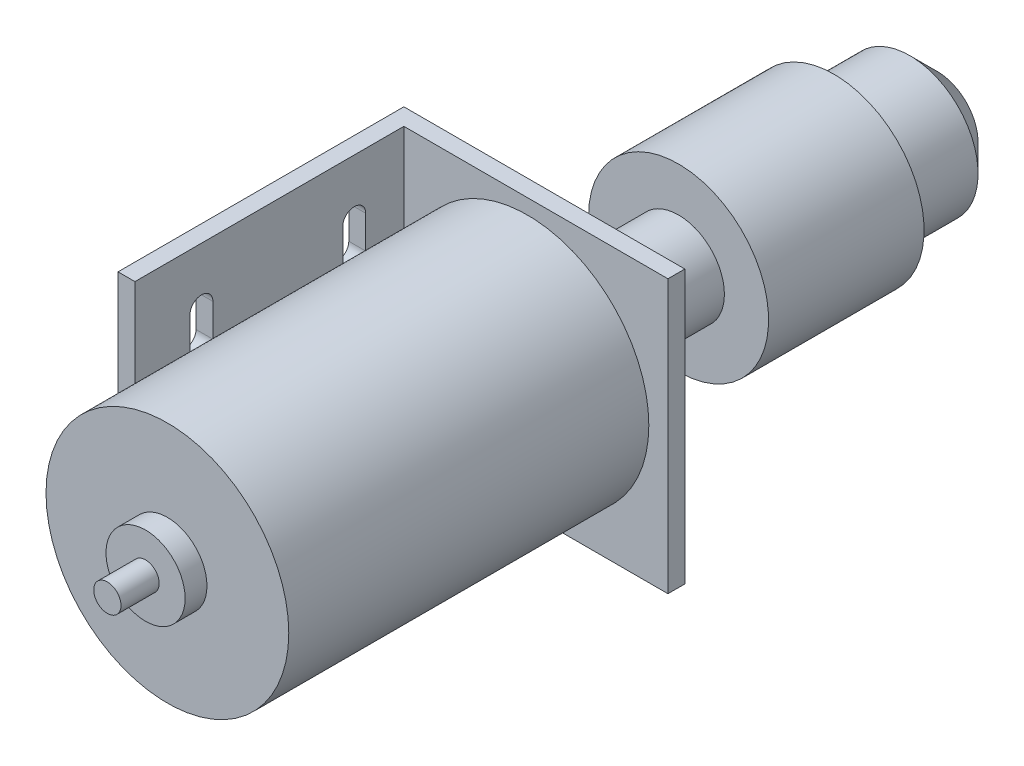
from build123d import *

# Parameters (mm, degrees)
SKETCH1_R           = 22.25
BOSS_EXTRUDE1_DEPTH = 66
SKETCH2_R           = 7.25
BOSS_EXTRUDE2_DEPTH = 4
SKETCH3_R           = 2.5
BOSS_EXTRUDE3_DEPTH = 7
SKETCH4_W           = 51.5
SKETCH4_H           = 50
SKETCH4_R           = 8.6
BOSS_EXTRUDE4_DEPTH = 3.1
SKETCH5_R           = 8.4
BOSS_EXTRUDE5_DEPTH = 27.7
SKETCH6_R           = 16.5
BOSS_EXTRUDE6_DEPTH = 28.5
SKETCH7_R           = 12.5
BOSS_EXTRUDE7_DEPTH = 18.9
SKETCH8_R           = 5.3
CUT_EXTRUDE1_DEPTH  = 26.4
CHAMFER1_SIZE       = 5
SKETCH9_W           = 3.1
SKETCH9_H           = 50
BOSS_EXTRUDE8_DEPTH = 49.3
CUT_EXTRUDE2_REACH  = 53.5


with BuildPart() as part:
    # Sketch1 → Boss-Extrude1 (new body)
    with BuildSketch(Plane.XY):
        Circle(SKETCH1_R)
    extrude(amount=BOSS_EXTRUDE1_DEPTH)

    # Sketch2 → Boss-Extrude2 (add)
    with BuildSketch(Plane.XY.offset(66)):
        Circle(SKETCH2_R)
    extrude(amount=BOSS_EXTRUDE2_DEPTH)

    # Sketch3 → Boss-Extrude3 (add)
    with BuildSketch(Plane.XY.offset(70)):
        Circle(SKETCH3_R)
    extrude(amount=BOSS_EXTRUDE3_DEPTH)

    # Sketch4 → Boss-Extrude4 (add)
    with BuildSketch(Plane(origin=(0, 0, 0), x_dir=(-1, 0, 0), z_dir=(0, 0, -1))):
        Rectangle(SKETCH4_W, SKETCH4_H)
        Circle(SKETCH4_R, mode=Mode.SUBTRACT)
    extrude(amount=BOSS_EXTRUDE4_DEPTH)

    # Sketch5 → Boss-Extrude5 (add)
    with BuildSketch(Plane(origin=(0, 0, 0), x_dir=(-1, 0, 0), z_dir=(0, 0, -1))):
        Circle(SKETCH5_R)
    extrude(amount=BOSS_EXTRUDE5_DEPTH)

    # Sketch6 → Boss-Extrude6 (add)
    with BuildSketch(Plane(origin=(0, 0, -27.7), x_dir=(-1, 0, 0), z_dir=(0, 0, -1))):
        Circle(SKETCH6_R)
    extrude(amount=BOSS_EXTRUDE6_DEPTH)

    # Sketch7 → Boss-Extrude7 (add)
    with BuildSketch(Plane(origin=(0, 0, -56.2), x_dir=(-1, 0, 0), z_dir=(0, 0, -1))):
        Circle(SKETCH7_R)
    extrude(amount=BOSS_EXTRUDE7_DEPTH)

    # Sketch8 → Cut-Extrude1 (cut)
    with BuildSketch(Plane(origin=(0, 0, -75.1), x_dir=(-1, 0, 0), z_dir=(0, 0, -1))):
        Circle(SKETCH8_R)
    extrude(amount=-CUT_EXTRUDE1_DEPTH, mode=Mode.SUBTRACT)

    # Chamfer1
    chamfer1_edges = [part.edges().sort_by_distance(p)[0] for p in [
        (12.5, 0, -75.1),
    ]]
    chamfer(chamfer1_edges, length=CHAMFER1_SIZE)

    # Sketch9 → Boss-Extrude8 (add)
    with BuildSketch(Plane.XY):
        with Locations((-24.2, 0)):
            Rectangle(SKETCH9_W, SKETCH9_H)
    extrude(amount=BOSS_EXTRUDE8_DEPTH)

    # Sketch10 → Cut-Extrude2 (cut, up to next)
    with BuildSketch(Plane.ZY.offset(25.75), mode=Mode.PRIVATE) as cut_extrude2_sk1:
        with BuildLine():
            Line((39.2, 14.7), (39.2, 8.7))
            ThreePointArc((39.2, 8.7), (37.1, 6.6), (35, 8.7))
            Line((35, 8.7), (35, 14.7))
            ThreePointArc((35, 14.7), (37.1, 16.8), (39.2, 14.7))
        make_face()
    cut_extrude2_tool1 = extrude(cut_extrude2_sk1.sketch, amount=-CUT_EXTRUDE2_REACH, mode=Mode.PRIVATE) & part.part
    add(cut_extrude2_tool1.solids().sort_by_distance((-25.75, 11.7, 37.1))[0], mode=Mode.SUBTRACT)
    # Sketch10 → Cut-Extrude2 (cut, up to next)
    with BuildSketch(Plane.ZY.offset(25.75), mode=Mode.PRIVATE) as cut_extrude2_sk2:
        with BuildLine():
            Line((39.2, -14.7), (39.2, -8.7))
            ThreePointArc((39.2, -8.7), (37.1, -6.6), (35, -8.7))
            Line((35, -8.7), (35, -14.7))
            ThreePointArc((35, -14.7), (37.1, -16.8), (39.2, -14.7))
        make_face()
    cut_extrude2_tool2 = extrude(cut_extrude2_sk2.sketch, amount=-CUT_EXTRUDE2_REACH, mode=Mode.PRIVATE) & part.part
    add(cut_extrude2_tool2.solids().sort_by_distance((-25.75, -11.7, 37.1))[0], mode=Mode.SUBTRACT)
    # Sketch10 → Cut-Extrude2 (cut, up to next)
    with BuildSketch(Plane.ZY.offset(25.75), mode=Mode.PRIVATE) as cut_extrude2_sk3:
        with BuildLine():
            Line((7, -14.7), (7, -8.7))
            ThreePointArc((7, -8.7), (9.1, -6.6), (11.2, -8.7))
            Line((11.2, -8.7), (11.2, -14.7))
            ThreePointArc((11.2, -14.7), (9.1, -16.8), (7, -14.7))
        make_face()
    cut_extrude2_tool3 = extrude(cut_extrude2_sk3.sketch, amount=-CUT_EXTRUDE2_REACH, mode=Mode.PRIVATE) & part.part
    add(cut_extrude2_tool3.solids().sort_by_distance((-25.75, -11.7, 9.1))[0], mode=Mode.SUBTRACT)
    # Sketch10 → Cut-Extrude2 (cut, up to next)
    with BuildSketch(Plane.ZY.offset(25.75), mode=Mode.PRIVATE) as cut_extrude2_sk4:
        with BuildLine():
            Line((7, 14.7), (7, 8.7))
            ThreePointArc((7, 8.7), (9.1, 6.6), (11.2, 8.7))
            Line((11.2, 8.7), (11.2, 14.7))
            ThreePointArc((11.2, 14.7), (9.1, 16.8), (7, 14.7))
        make_face()
    cut_extrude2_tool4 = extrude(cut_extrude2_sk4.sketch, amount=-CUT_EXTRUDE2_REACH, mode=Mode.PRIVATE) & part.part
    add(cut_extrude2_tool4.solids().sort_by_distance((-25.75, 11.7, 9.1))[0], mode=Mode.SUBTRACT)


solid = part.part
